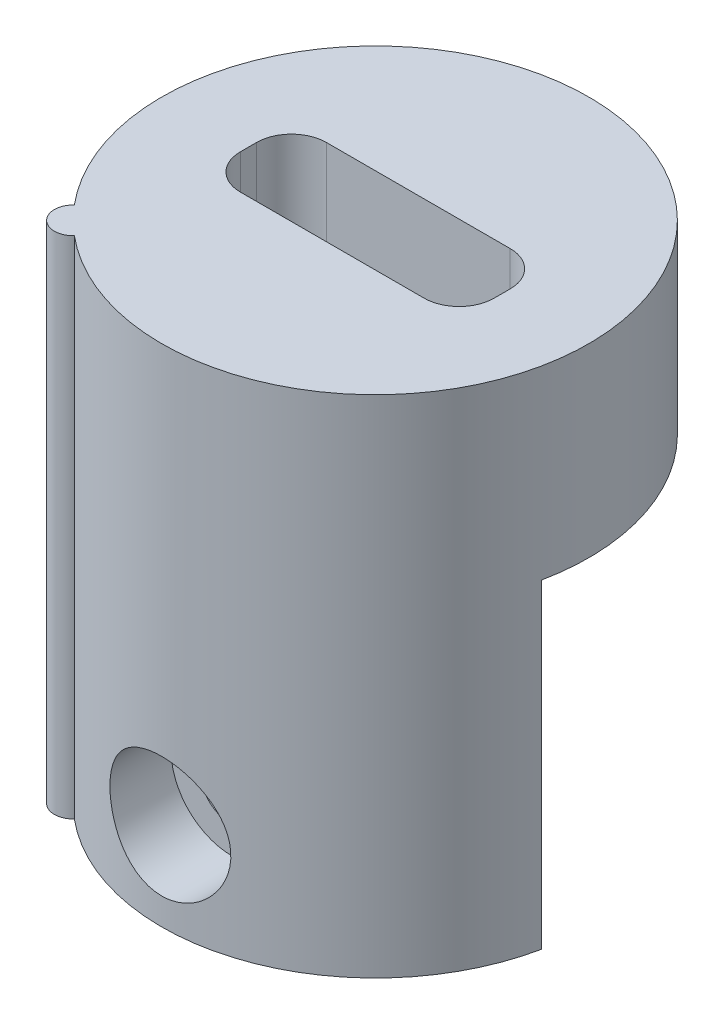
from build123d import *

# Parameters (mm, degrees)
BOSS_EXTRUDE1_DEPTH = 18.8
CUT_EXTRUDE2_DEPTH  = 11.9
BOSS_EXTRUDE2_DEPTH = 6.4
SKETCH9_R           = 1.2075
CUT_EXTRUDE3_DEPTH  = 2.5
SKETCH9_4_R         = 3.05
SKETCH9_4_R_2       = 1.2075
BOSS_EXTRUDE5_DEPTH = 4
SKETCH11_R          = 2.25
CUT_EXTRUDE8_DEPTH  = 3.6
BOSS_EXTRUDE6_DEPTH = 4.5
CUT_EXTRUDE9_DEPTH  = 11.9
CUT_EXTRUDE10_DEPTH = 11.9


with BuildPart() as part:
    # Sketch2 → Boss-Extrude1 (new body)
    with BuildSketch(Plane(origin=(0, 0, 0), x_dir=(1, 0, 0), z_dir=(0, 1, 0))):
        with BuildLine():
            ThreePointArc((-5.105212739, -6.0942024), (5.62149891, 5.62149891), (-6.0942024, -5.105212739))
            ThreePointArc((-6.0942024, -5.105212739), (-6.116473657, -6.116473657), (-5.105212739, -6.0942024))
        make_face()
        with BuildLine():
            Line((-3.42, 1.6), (3.42, 1.6))
            ThreePointArc((3.42, 1.6), (4.339238816, 1.219238816), (4.72, 0.3))
            Line((4.72, 0.3), (4.72, -0.3))
            ThreePointArc((4.72, -0.3), (4.339238816, -1.219238816), (3.42, -1.6))
            Line((3.42, -1.6), (-3.42, -1.6))
            ThreePointArc((-3.42, -1.6), (-4.339238816, -1.219238816), (-4.72, -0.3))
            Line((-4.72, -0.3), (-4.72, 0.3))
            ThreePointArc((-4.72, 0.3), (-4.339238816, 1.219238816), (-3.42, 1.6))
        make_face(mode=Mode.SUBTRACT)
    extrude(amount=BOSS_EXTRUDE1_DEPTH)

    # Sketch3 → Cut-Extrude2 (cut)
    with BuildSketch(Plane(origin=(0, 0, 0), x_dir=(1, 0, 0), z_dir=(0, 1, 0))):
        with BuildLine():
            Line((-5.98, 3.733912158), (-5.98, -3.733912158))
            ThreePointArc((-5.98, -3.733912158), (-4.924640659, -5.044840372), (-3.588648771, -6.068286414))
            ThreePointArc((-3.588648771, -6.068286414), (3.493030644, -6.12382535), (7.05, 0))
            ThreePointArc((7.05, 0), (1.94209938, 6.777222883), (-5.98, 3.733912158))
        make_face()
        with BuildLine():
            Line((-4.72, -0.3), (-4.72, 0.3))
            ThreePointArc((-4.72, 0.3), (-4.339238816, 1.219238816), (-3.42, 1.6))
            Line((-3.42, 1.6), (3.42, 1.6))
            ThreePointArc((3.42, 1.6), (4.339238816, 1.219238816), (4.72, 0.3))
            Line((4.72, 0.3), (4.72, -0.3))
            ThreePointArc((4.72, -0.3), (4.339238816, -1.219238816), (3.42, -1.6))
            Line((3.42, -1.6), (-3.42, -1.6))
            ThreePointArc((-3.42, -1.6), (-4.339238816, -1.219238816), (-4.72, -0.3))
        make_face(mode=Mode.SUBTRACT)
    extrude(amount=CUT_EXTRUDE2_DEPTH, mode=Mode.SUBTRACT)

    # Sketch4 → Boss-Extrude2 (add)
    with BuildSketch(Plane.XZ):
        with BuildLine():
            Line((-2.25, 6.681317235), (-2.25, 2.85))
            Line((-2.25, 2.85), (2.25, 2.85))
            Line((2.25, 2.85), (2.25, 6.681317235))
            ThreePointArc((2.25, 6.681317235), (0, 7.05), (-2.25, 6.681317235))
        make_face()
    extrude(amount=-BOSS_EXTRUDE2_DEPTH)

    # Sketch9 → Cut-Extrude3 (cut)
    with BuildSketch(Plane(origin=(0, 0, 2.85), x_dir=(-1, 0, 0), z_dir=(0, 0, -1))):
        with Locations((0, 3.2)):
            Circle(SKETCH9_R)
    extrude(amount=-CUT_EXTRUDE3_DEPTH, mode=Mode.SUBTRACT)

    # Sketch9_4 → Boss-Extrude5 (add)
    with BuildSketch(Plane(origin=(0, 0, 2.85), x_dir=(-1, 0, 0), z_dir=(0, 0, -1))):
        with Locations((0, 3.2)):
            Circle(SKETCH9_4_R)
        with Locations((0, 3.2)):
            Circle(SKETCH9_4_R_2, mode=Mode.SUBTRACT)
    extrude(amount=-BOSS_EXTRUDE5_DEPTH)

    # Sketch11 → Cut-Extrude8 (cut, through all)
    with BuildSketch(Plane(origin=(0, 0, 5.35), x_dir=(-1, 0, 0), z_dir=(0, 0, -1))):
        with Locations((0, 3.25)):
            Circle(SKETCH11_R)
    extrude(amount=-CUT_EXTRUDE8_DEPTH, mode=Mode.SUBTRACT)

    # Sketch15 → Boss-Extrude6 (add)
    with BuildSketch(Plane.ZY.offset(2.25)):
        Polygon((2.85, 6.4), (7.35, 6.4), (7.35, 10.9), align=None)
    extrude(amount=-BOSS_EXTRUDE6_DEPTH)

    # Sketch3_3 → Cut-Extrude9 (cut)
    with BuildSketch(Plane(origin=(0, 0, 0), x_dir=(1, 0, 0), z_dir=(0, 1, 0))):
        with BuildLine():
            ThreePointArc((-5.98, 3.733912158), (-7.05, 0), (-5.98, -3.733912158))
            Line((-5.98, -3.733912158), (-5.98, 3.733912158))
        make_face()
    extrude(amount=CUT_EXTRUDE9_DEPTH, mode=Mode.SUBTRACT)

    # Sketch16 → Cut-Extrude10 (cut)
    with BuildSketch(Plane.XZ):
        Polygon((7.95, -7.95), (-7.95, -7.95), (-7.95, 0), (-7.95, 1.6), (7.95, 1.6), (7.95, 0), align=None)
    extrude(amount=-CUT_EXTRUDE10_DEPTH, mode=Mode.SUBTRACT)


solid = part.part
